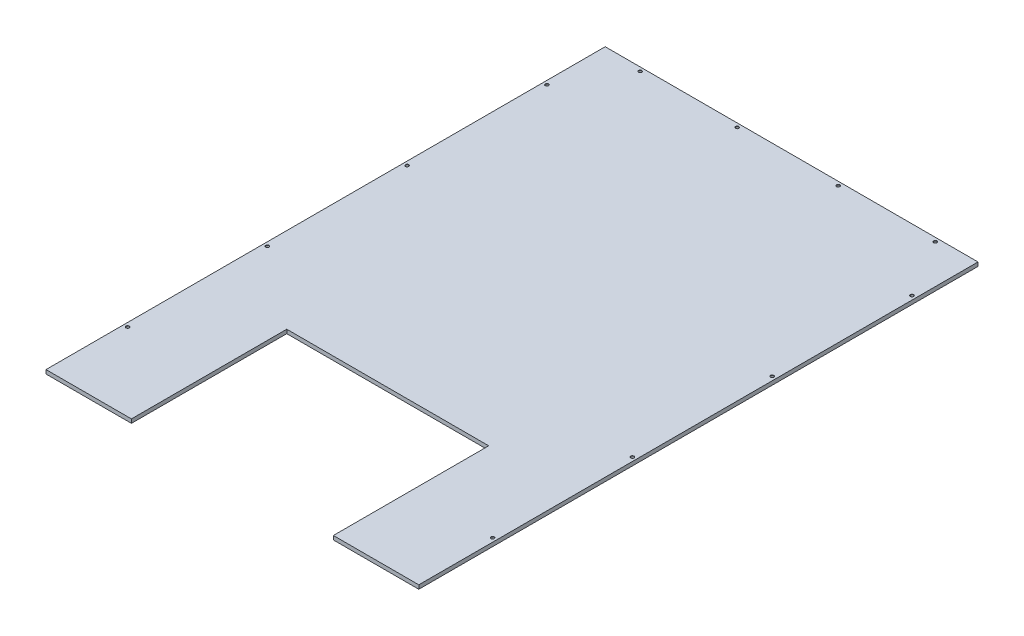
from build123d import *

# Parameters (mm, degrees)
SKETCH1_W                              = 1219.2
SKETCH1_H                              = 12.7
BOSS_EXTRUDE1_DEPTH                    = 1828.8
SKETCH2_W                              = 660.4
SKETCH2_H                              = 508
CUT_EXTRUDE1_DEPTH                     = 13.7
F_3_8_0_375_DIAMETER_HOLE1_D           = 9.525
F_3_8_0_375_DIAMETER_HOLE1_CSINK_D     = 10.795
F_3_8_0_375_DIAMETER_HOLE1_CSINK_ANGLE = 90


with BuildPart() as part:
    # Sketch1 → Boss-Extrude1 (new body)
    with BuildSketch(Plane.XY):
        with Locations((609.6, 6.35)):
            Rectangle(SKETCH1_W, SKETCH1_H)
    extrude(amount=BOSS_EXTRUDE1_DEPTH)

    # Sketch2 → Cut-Extrude1 (cut, through all)
    with BuildSketch(Plane(origin=(0, 12.7, 0), x_dir=(1, 0, 0), z_dir=(0, 1, 0))):
        with Locations((609.6, -1574.8)):
            Rectangle(SKETCH2_W, SKETCH2_H)
    extrude(amount=-CUT_EXTRUDE1_DEPTH, mode=Mode.SUBTRACT)

    # 3/8 (0.375) Diameter Hole1 (through all)
    with Locations(Plane(origin=(0, 12.7, 0), x_dir=(1, 0, 0), z_dir=(0, 1, 0))):
        with Locations((1206.5, -1574.8), (1206.5, -1117.6), (1206.5, -660.4), (1206.5, -203.2), (12.7, -1574.8), (12.7, -1117.6), (12.7, -660.4), (12.7, -203.2), (444.5, -12.7), (127, -12.7), (1092.2, -12.7), (774.7, -12.7)):
            CounterSinkHole(F_3_8_0_375_DIAMETER_HOLE1_D / 2, F_3_8_0_375_DIAMETER_HOLE1_CSINK_D / 2, counter_sink_angle=F_3_8_0_375_DIAMETER_HOLE1_CSINK_ANGLE)


solid = part.part
